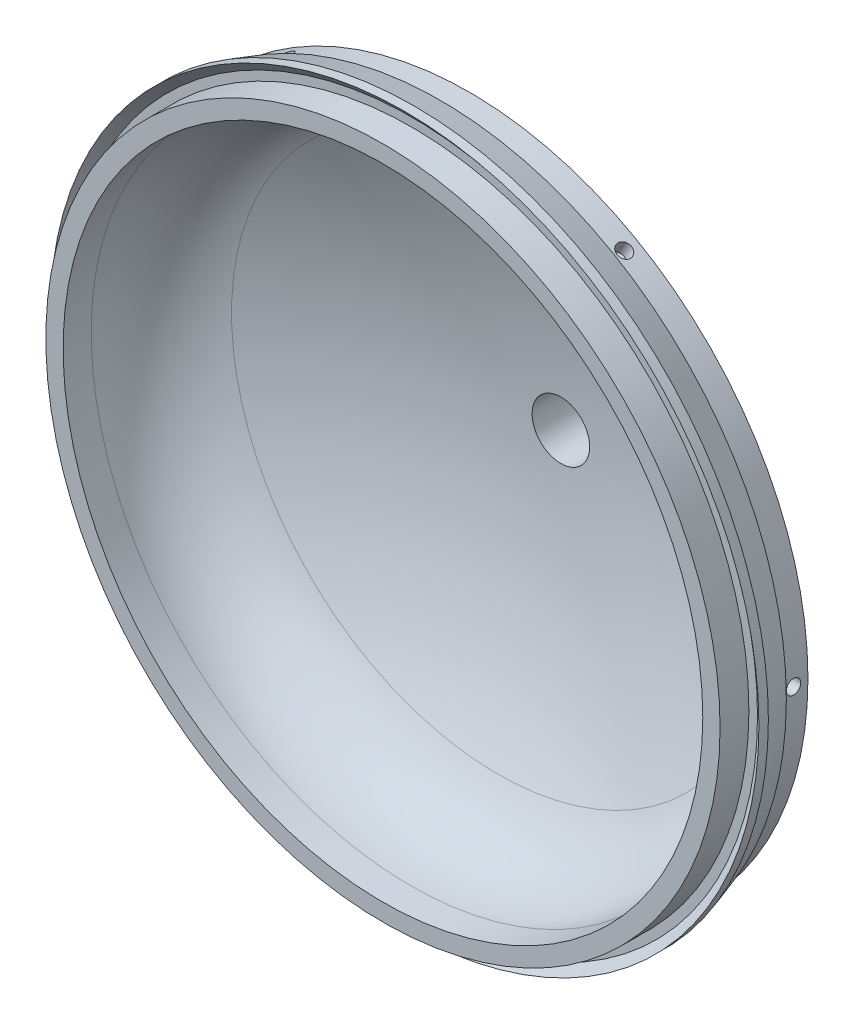
from build123d import *

# Parameters (mm, degrees)
BOSS_EXTRUDE2_REACH = 98.52
SKETCH10_R          = 25.4
SKETCH11_R          = 12.7
CUT_EXTRUDE1_DEPTH  = 190.754
CIRPATTERN1_COUNT   = 6


with BuildPart() as part:
    # Sketch1 → Revolve1 (revolve)
    with BuildSketch(Plane(origin=(0, 0, 0), x_dir=(1, 0, 0), z_dir=(0, 1, 0))):
        with BuildLine():
            Line((-148.59, 0), (-140.97, 0))
            Line((-140.97, 0), (-140.97, 12.391039743))
            ThreePointArc((-140.97, 12.391039743), (-134.615921102, 34.866271953), (-117.434796957, 50.687755913))
            ThreePointArc((-117.434796957, 50.687755913), (-60.367509579, 71.617582047), (0, 78.72368491))
            Line((0, 78.72368491), (0, 85.07368491))
            ThreePointArc((0, 85.07368491), (-61.842045719, 77.794008454), (-120.303258046, 56.352950612))
            ThreePointArc((-120.303258046, 56.352950612), (-131.462846302, 48.602983737), (-140.081763243, 38.1))
            Line((-140.081763243, 38.1), (-149.225, 38.1))
            Line((-149.225, 38.1), (-149.225, 25.4))
            Line((-149.225, 25.4), (-152.4, 25.4))
            Line((-152.4, 25.4), (-156.21, 13.674025723))
            Line((-156.21, 13.674025723), (-156.21, 9.503030405))
            Line((-156.21, 9.503030405), (-152.4, 12.7))
            Line((-152.4, 12.7), (-148.59, 12.7))
            Line((-148.59, 12.7), (-148.59, 0))
        make_face()
    revolve(axis=Axis((0, 0, -78.72368491), (0, 0, -1)))

    # Sketch10 → Boss-Extrude2 (add, up to next)
    with BuildSketch(Plane.XY.offset(-96.52), mode=Mode.PRIVATE) as boss_extrude2_sk1:
        Circle(SKETCH10_R)
    boss_extrude2_tool1 = extrude(boss_extrude2_sk1.sketch, amount=BOSS_EXTRUDE2_REACH, mode=Mode.PRIVATE) - part.part
    add(boss_extrude2_tool1.solids().sort_by_distance((0, 0, -96.52))[0])

    # Sketch11 → Cut-Extrude1 (cut)
    with BuildSketch(Plane.XY):
        Circle(SKETCH11_R)
    extrude(amount=-CUT_EXTRUDE1_DEPTH, mode=Mode.SUBTRACT)

    # Sketch15 → 1/4 (0.25) Diameter Hole1 (revolve, cut)
    with BuildSketch(Plane(origin=(149.225, 0, -31.75), x_dir=(0, 0, -1), z_dir=(0, 1, 0))):
        Polygon((0, 0), (0, 8.257732465), (3.175, 6.35), (3.175, 0), align=None)
    f_1_4_0_25_diameter_hole1 = revolve(axis=Axis((155.575, 0, -31.75), (-1, 0, 0)), mode=Mode.SUBTRACT)

    # CirPattern1: 1/4 (0.25) Diameter Hole1 ×6 about axis
    cirpattern1_axis = Axis((0, 0, 5.473137056), (0, 0, -1))
    for i in range(1, CIRPATTERN1_COUNT):
        add(f_1_4_0_25_diameter_hole1.rotate(cirpattern1_axis, i * 360 / CIRPATTERN1_COUNT), mode=Mode.SUBTRACT)


solid = part.part
